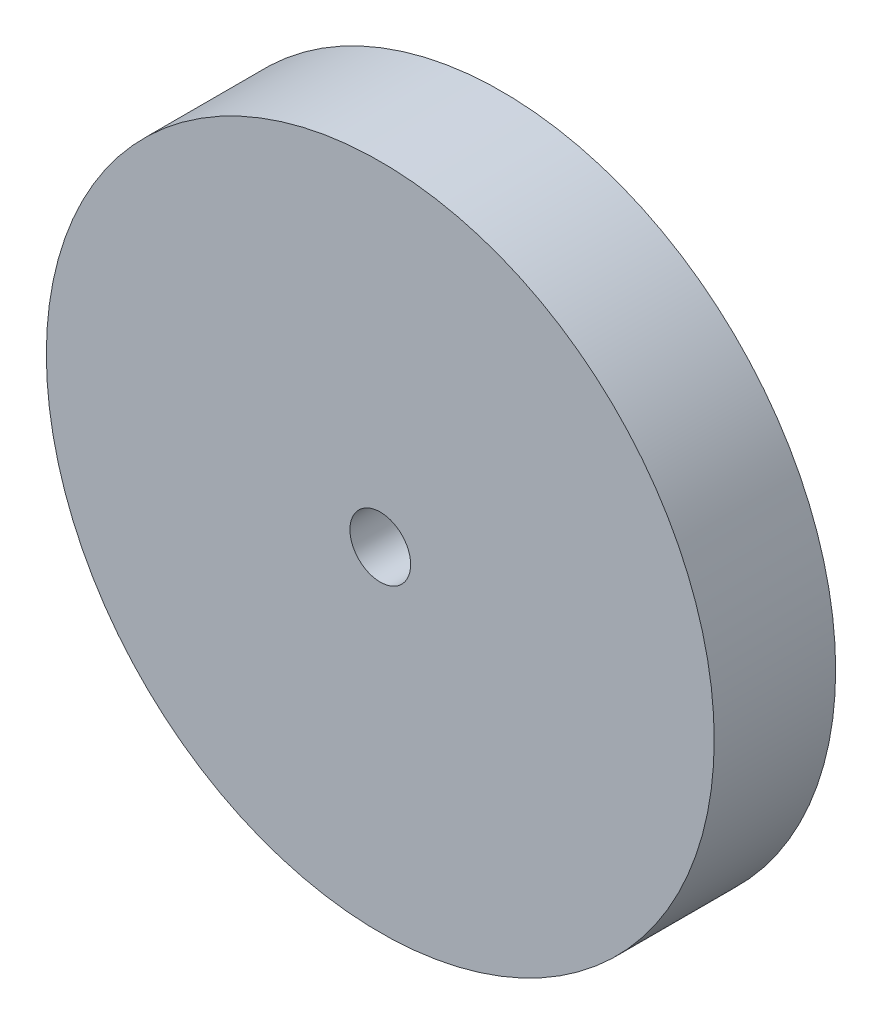
from build123d import *

# Parameters (mm, degrees)
SKETCH_1_R          = 11
EXTRUDE_1_DEPTH     = 4
SKETCH_2_R          = 1
CUT_EXTRUDE_1_DEPTH = 5


with BuildPart() as part:
    # 草图1 → 凸台-拉伸1 (new body)
    with BuildSketch(Plane.XY):
        Circle(SKETCH_1_R)
    extrude(amount=EXTRUDE_1_DEPTH)

    # 草图2 → 切除-拉伸1 (cut, through all)
    with BuildSketch(Plane.XY.offset(4)):
        Circle(SKETCH_2_R)
    extrude(amount=-CUT_EXTRUDE_1_DEPTH, mode=Mode.SUBTRACT)


solid = part.part
